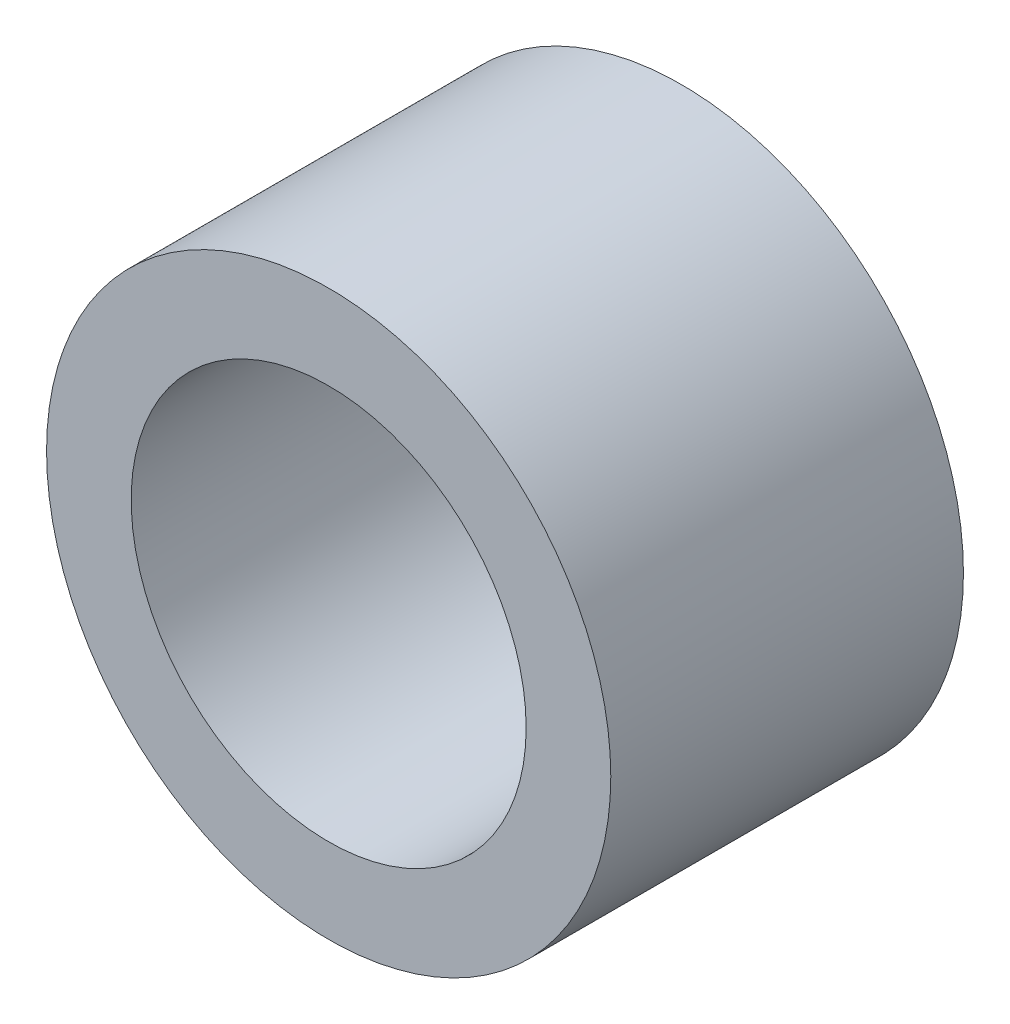
from build123d import *

# Parameters (mm, degrees)
SKETCH1_R           = 8
SKETCH1_R_2         = 5.6
BOSS_EXTRUDE1_DEPTH = 10


with BuildPart() as part:
    # Sketch1 → Boss-Extrude1 (new body)
    with BuildSketch(Plane.XY):
        Circle(SKETCH1_R)
        Circle(SKETCH1_R_2, mode=Mode.SUBTRACT)
    extrude(amount=BOSS_EXTRUDE1_DEPTH)


solid = part.part
